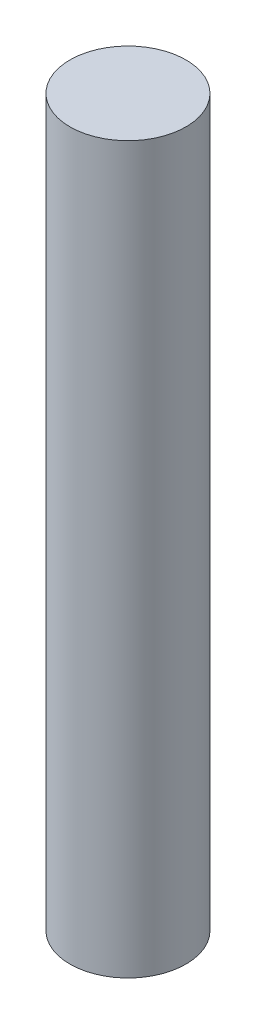
from build123d import *

# Parameters (mm, degrees)
SKETCH1_R           = 4
BOSS_EXTRUDE1_DEPTH = 25


with BuildPart() as part:
    # Sketch1 → Boss-Extrude1 (new body, symmetric)
    with BuildSketch(Plane(origin=(0, 0, 0), x_dir=(1, 0, 0), z_dir=(0, 1, 0))):
        Circle(SKETCH1_R)
    extrude(amount=BOSS_EXTRUDE1_DEPTH, both=True)


solid = part.part
